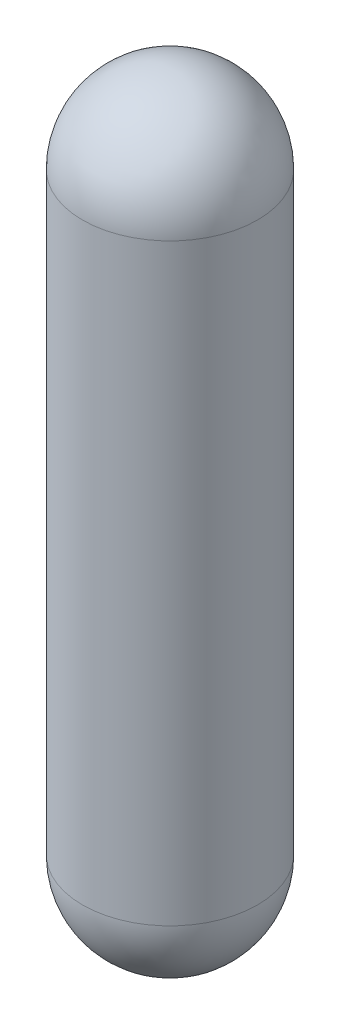
from build123d import *


with BuildPart() as part:
    # Sketch1 → Revolve1 (revolve)
    with BuildSketch(Plane.XY):
        with BuildLine():
            Line((0, 43.5), (0, -43.5))
            Line((0, -43.5), (0, -56.333333333))
            ThreePointArc((0, -56.333333333), (9.074537025, -52.574537025), (12.833333333, -43.5))
            Line((12.833333333, -43.5), (12.833333333, 43.5))
            ThreePointArc((12.833333333, 43.5), (9.074537025, 52.574537025), (0, 56.333333333))
            Line((0, 56.333333333), (0, 43.5))
        make_face()
    revolve(axis=Axis((0, 43.5, 0), (0, -1, 0)))


solid = part.part
